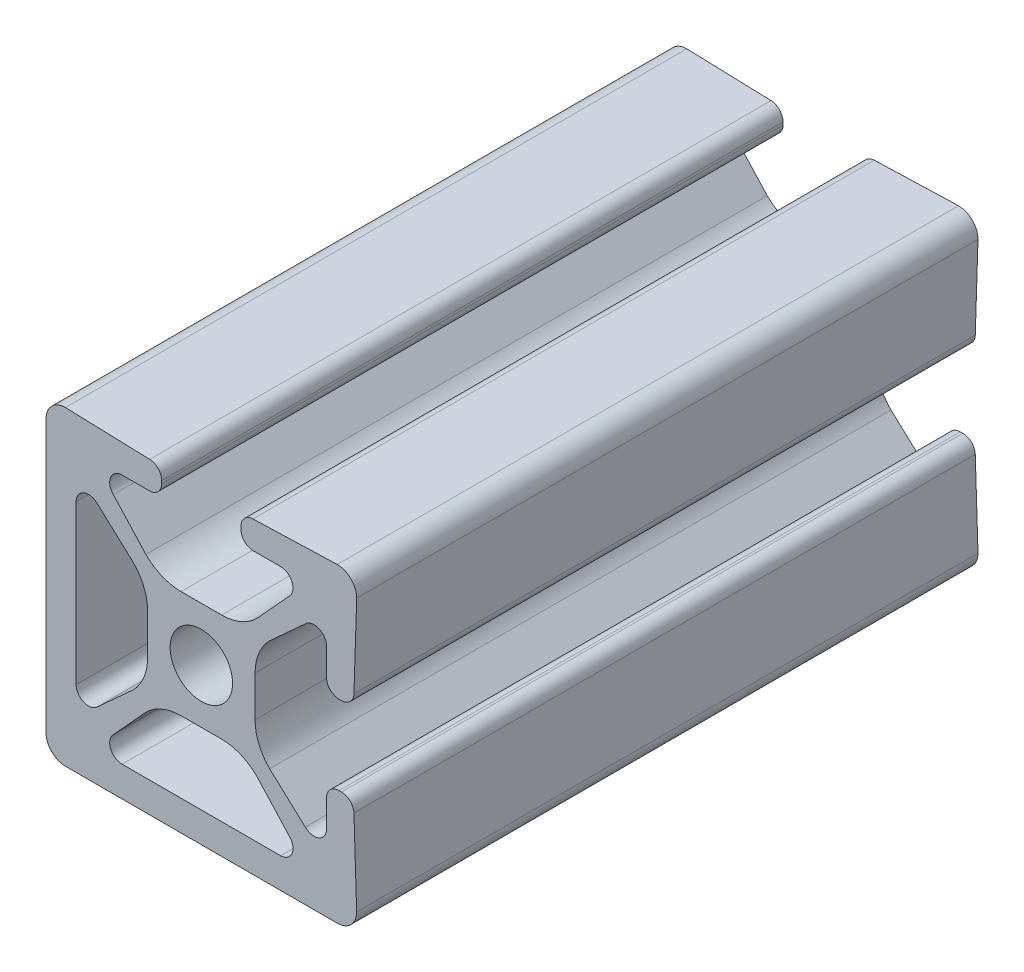
from build123d import *

# Parameters (mm, degrees)
SKETCH1_R      = 1.27635
EXTRUDE1_DEPTH = 25.4


with BuildPart() as part:
    # Sketch1 → Extrude1 (new body)
    with BuildSketch(Plane.XY):
        with BuildLine():
            Line((-2.266074779, 2.792259021), (-3.597719195, 4.250869712))
            ThreePointArc((-3.597719195, 4.250869712), (-3.707979565, 4.804147382), (-3.239236773, 5.118080056))
            Line((-3.239236773, 5.118080056), (-2.12725, 5.1181))
            ThreePointArc((-2.12725, 5.1181), (-1.768039755, 5.266889755), (-1.61925, 5.6261))
            Line((-1.61925, 5.6261), (-1.61925, 5.731127227))
            ThreePointArc((-1.61925, 5.731127227), (-1.762294622, 6.084500719), (-2.110872134, 6.238864921))
            Line((-2.110872134, 6.238864921), (-5.55625, 6.3499873))
            ThreePointArc((-5.55625, 6.3499873), (-6.117516008, 6.117503308), (-6.35, 5.5562373))
            Line((-6.35, 5.5562373), (-6.35, -5.55625))
            ThreePointArc((-6.35, -5.55625), (-6.117516008, -6.117516008), (-5.55625, -6.35))
            Line((-5.55625, -6.35), (5.55625, -6.35))
            ThreePointArc((5.55625, -6.35), (6.117516008, -6.117516008), (6.35, -5.55625))
            Line((6.35, -5.55625), (6.2388496, -2.110867))
            ThreePointArc((6.2388496, -2.110867), (6.084481448, -1.762300959), (5.73111497, -1.6192627))
            Line((5.73111497, -1.6192627), (5.6261, -1.6192627))
            ThreePointArc((5.6261, -1.6192627), (5.266889755, -1.768052455), (5.1181, -2.1272627))
            Line((5.1181, -2.1272627), (5.118086781, -3.239226147))
            ThreePointArc((5.118086781, -3.239226147), (4.804155079, -3.707969591), (4.250877181, -3.59771037))
            Line((4.250877181, -3.59771037), (2.7922601, -2.2660864))
            ThreePointArc((2.7922601, -2.2660864), (2.351781222, -1.606857234), (2.1971, -0.8292465))
            Line((2.1971, -0.8292465), (2.1971, 0.8292338))
            ThreePointArc((2.1971, 0.8292338), (2.35177885, 1.606851508), (2.792259021, 2.266087479))
            Line((2.792259021, 2.266087479), (4.250877574, 3.596983984))
            ThreePointArc((4.250877574, 3.596983984), (4.804155516, 3.707243364), (5.1180873, 3.238499886))
            Line((5.1180873, 3.238499886), (5.1181, 2.12725))
            ThreePointArc((5.1181, 2.12725), (5.266889755, 1.768039755), (5.6261, 1.61925))
            Line((5.6261, 1.61925), (5.731114527, 1.61925))
            ThreePointArc((5.731114527, 1.61925), (6.084488115, 1.762294714), (6.23885223, 2.1108724))
            Line((6.23885223, 2.1108724), (6.35, 5.55625))
            ThreePointArc((6.35, 5.55625), (6.117516008, 6.117516008), (5.55625, 6.35))
            Line((5.55625, 6.35), (2.110872134, 6.238864921))
            ThreePointArc((2.110872134, 6.238864921), (1.762294622, 6.084500719), (1.61925, 5.731127227))
            Line((1.61925, 5.731127227), (1.61925, 5.6261))
            ThreePointArc((1.61925, 5.6261), (1.768039755, 5.266889755), (2.12725, 5.1181))
            Line((2.12725, 5.1181), (3.238489261, 5.118094023))
            ThreePointArc((3.238489261, 5.118094023), (3.70723339, 4.804163213), (3.596975159, 4.250885042))
            Line((3.596975159, 4.250885042), (2.266081683, 2.792263725))
            ThreePointArc((2.266081683, 2.792263725), (1.606847146, 2.351789743), (0.8292338, 2.1971127))
            Line((0.8292338, 2.1971127), (-0.8292338, 2.1971))
            ThreePointArc((-0.8292338, 2.1971), (-1.606846535, 2.35177679), (-2.266074779, 2.792259021))
        make_face()
        Circle(SKETCH1_R, mode=Mode.SUBTRACT)
        with BuildLine():
            Line((-5.1180873, -3.238499886), (-5.118086781, 3.239226147))
            ThreePointArc((-5.118086781, 3.239226147), (-4.804155079, 3.707969591), (-4.250877181, 3.59771037))
            Line((-4.250877181, 3.59771037), (-2.792246321, 2.266087479))
            ThreePointArc((-2.792246321, 2.266087479), (-2.35176409, 1.606859235), (-2.1970873, 0.8292465))
            Line((-2.1970873, 0.8292465), (-2.1971, -0.8292465))
            ThreePointArc((-2.1971, -0.8292465), (-2.35177679, -1.606859235), (-2.792259021, -2.266087479))
            Line((-2.792259021, -2.266087479), (-4.250877574, -3.596983984))
            ThreePointArc((-4.250877574, -3.596983984), (-4.804155516, -3.707243364), (-5.1180873, -3.238499886))
        make_face(mode=Mode.SUBTRACT)
        with BuildLine():
            Line((0.8292465, -2.1970873), (-0.8292465, -2.1971))
            ThreePointArc((-0.8292465, -2.1971), (-1.606859235, -2.35177679), (-2.266087479, -2.792259021))
            Line((-2.266087479, -2.792259021), (-3.596983984, -4.250877574))
            ThreePointArc((-3.596983984, -4.250877574), (-3.707243364, -4.804155516), (-3.238499886, -5.1180873))
            Line((-3.238499886, -5.1180873), (3.239226147, -5.118086781))
            ThreePointArc((3.239226147, -5.118086781), (3.707969591, -4.804155079), (3.59771037, -4.250877181))
            Line((3.59771037, -4.250877181), (2.266087479, -2.792246321))
            ThreePointArc((2.266087479, -2.792246321), (1.606859235, -2.35176409), (0.8292465, -2.1970873))
        make_face(mode=Mode.SUBTRACT)
    extrude(amount=EXTRUDE1_DEPTH)


solid = part.part
